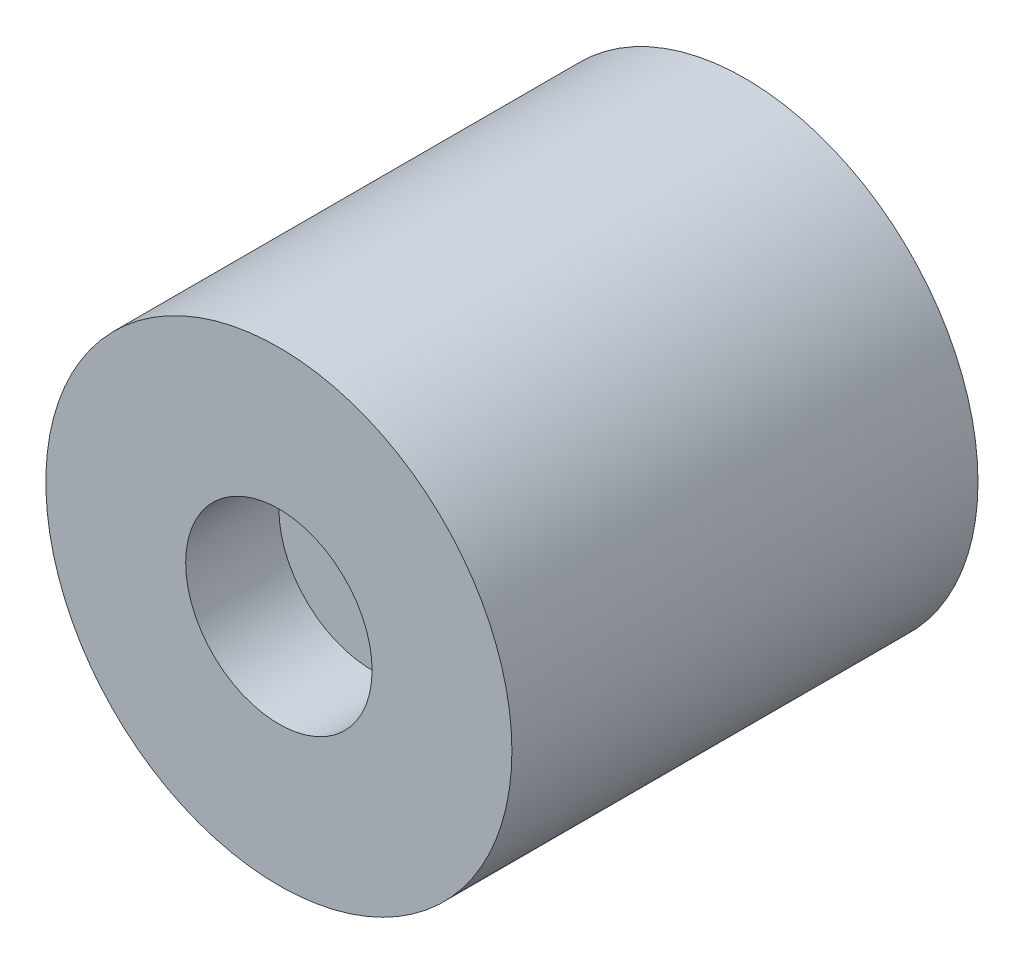
from build123d import *

# Parameters (mm, degrees)
ESQUISSE1_R             = 12.5
BOSS_EXTRU_1_DEPTH      = 25
ESQUISSE3_R             = 5
ENL_V_MAT_EXTRU_1_DEPTH = 5


with BuildPart() as part:
    # Esquisse1 → Boss.-Extru.1 (new body)
    with BuildSketch(Plane.XY):
        Circle(ESQUISSE1_R)
    extrude(amount=BOSS_EXTRU_1_DEPTH)

    # Esquisse3 → Enlèv. mat.-Extru.1 (cut)
    with BuildSketch(Plane.XY.offset(25)):
        Circle(ESQUISSE3_R)
    extrude(amount=-ENL_V_MAT_EXTRU_1_DEPTH, mode=Mode.SUBTRACT)


solid = part.part
